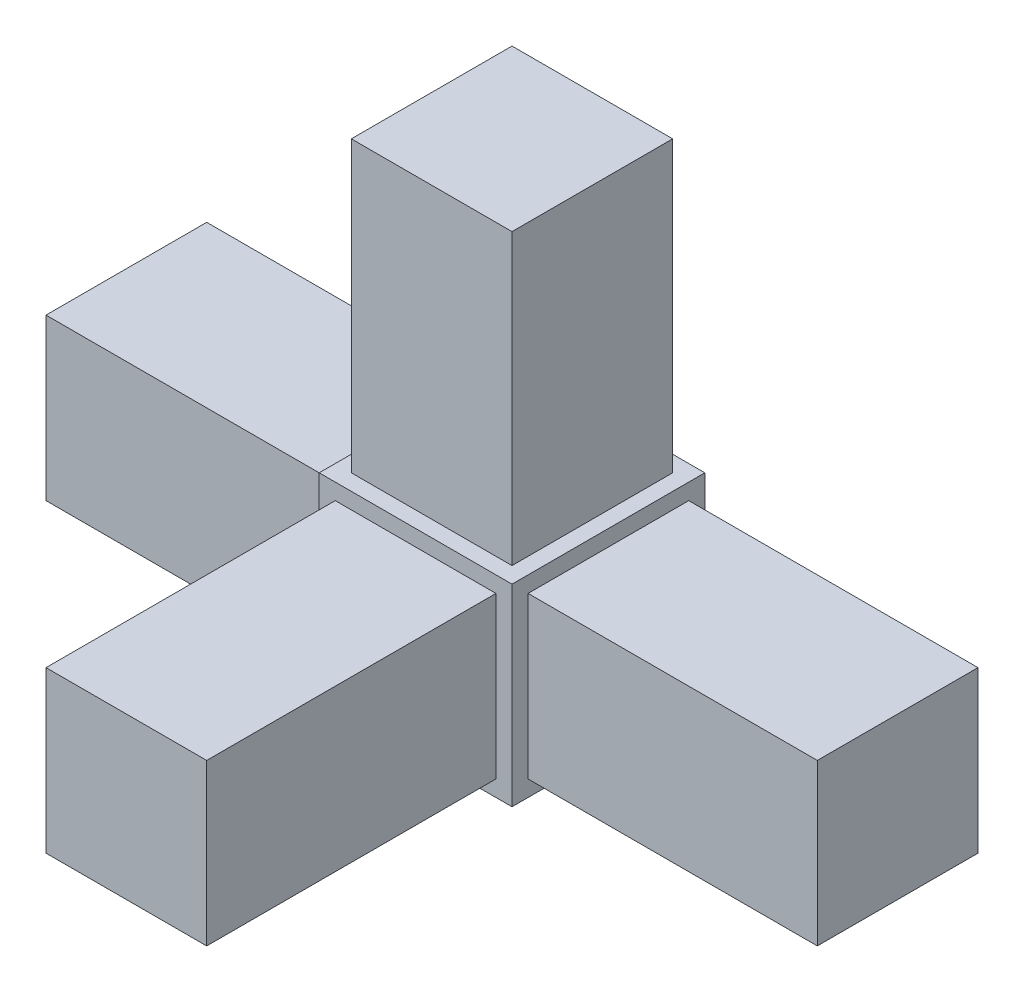
from build123d import *

# Parameters (mm, degrees)
SKETCH1_W           = 19.05
SKETCH1_H           = 19.05
BOSS_EXTRUDE1_DEPTH = 19.05
SKETCH2_W           = 15.875
SKETCH2_H           = 15.875
BOSS_EXTRUDE2_DEPTH = 28.575
SKETCH3_W           = 15.875
SKETCH3_H           = 15.875
BOSS_EXTRUDE3_DEPTH = 28.575
SKETCH4_W           = 15.875
SKETCH4_H           = 15.875
BOSS_EXTRUDE4_DEPTH = 28.575
SKETCH5_W           = 15.875
SKETCH5_H           = 15.875
BOSS_EXTRUDE5_DEPTH = 28.575


with BuildPart() as part:
    # Sketch1 → Boss-Extrude1 (new body)
    with BuildSketch(Plane.XY):
        Rectangle(SKETCH1_W, SKETCH1_H)
    extrude(amount=BOSS_EXTRUDE1_DEPTH)

    # Sketch2 → Boss-Extrude2 (add)
    with BuildSketch(Plane(origin=(0, 9.525, 0), x_dir=(1, 0, 0), z_dir=(0, 1, 0))):
        with Locations((0, -9.525)):
            Rectangle(SKETCH2_W, SKETCH2_H)
    extrude(amount=BOSS_EXTRUDE2_DEPTH)

    # Sketch3 → Boss-Extrude3 (add)
    with BuildSketch(Plane(origin=(9.525, 0, 0), x_dir=(0, 0, -1), z_dir=(1, 0, 0))):
        with Locations((-9.525, 0)):
            Rectangle(SKETCH3_W, SKETCH3_H)
    extrude(amount=BOSS_EXTRUDE3_DEPTH)

    # Sketch4 → Boss-Extrude4 (add)
    with BuildSketch(Plane.XY.offset(19.05)):
        Rectangle(SKETCH4_W, SKETCH4_H)
    extrude(amount=BOSS_EXTRUDE4_DEPTH)

    # Sketch5 → Boss-Extrude5 (add)
    with BuildSketch(Plane.ZY.offset(9.525)):
        with Locations((9.525, 0)):
            Rectangle(SKETCH5_W, SKETCH5_H)
    extrude(amount=BOSS_EXTRUDE5_DEPTH)


solid = part.part
